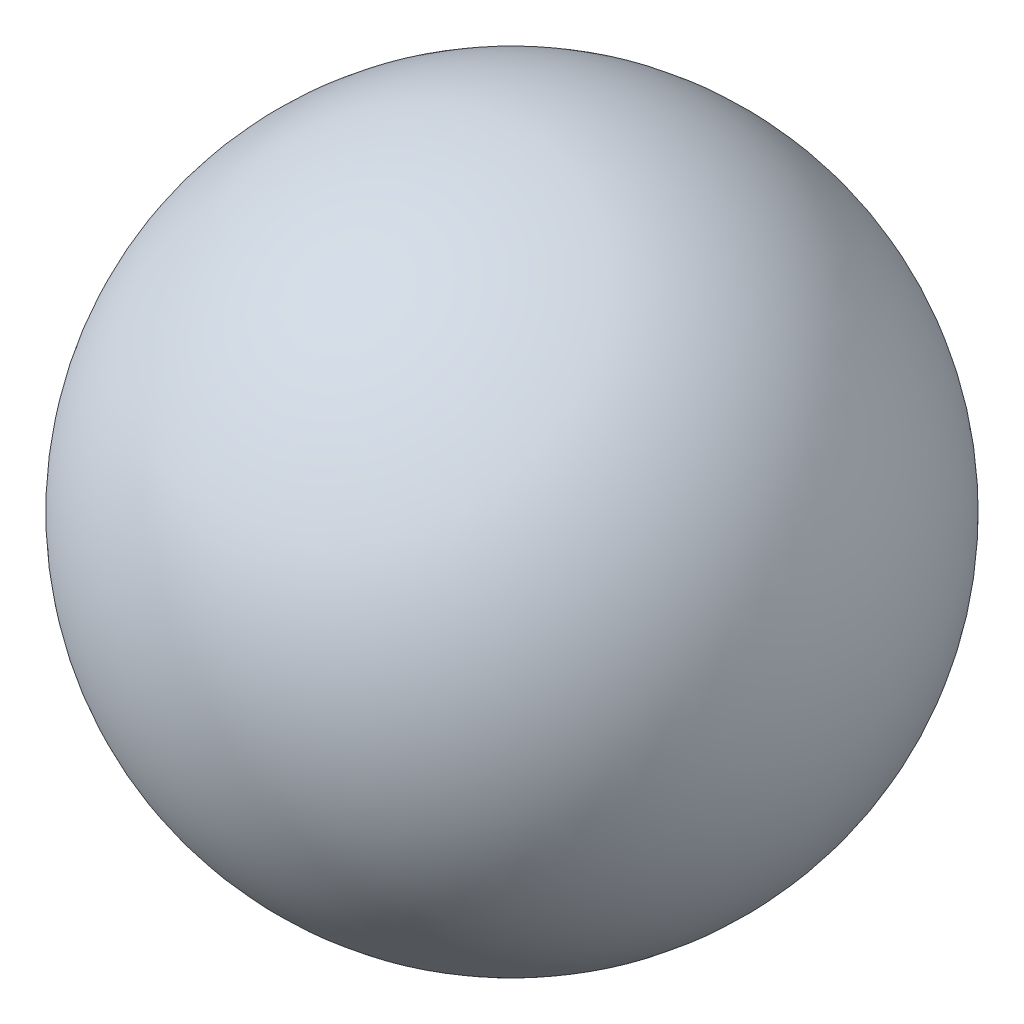
from build123d import *

# Parameters (mm, degrees)
SKIZZE3_R     = 1.5
SKIZZE3_R_2   = 0.5
ACHSE_1_DEPTH = 5
SKIZZE4_R     = 1.5
SKIZZE4_R_2   = 0.5
ACHSE_2_DEPTH = 5


with BuildPart() as part:
    # Skizze2 → Kugel (revolve)
    with BuildSketch(Plane(origin=(0, 0, 0), x_dir=(0, 0, -1), z_dir=(1, 0, 0))):
        with BuildLine():
            Line((0, 6), (0, -6))
            ThreePointArc((0, -6), (6, 0), (0, 6))
        make_face()
    revolve(axis=Axis((0, 23.376095618, 0), (0, -1, 0)))

    # Skizze3 → Achse 1 (cut, symmetric)
    with BuildSketch(Plane(origin=(0, 0, 0), x_dir=(0, 0, -1), z_dir=(1, 0, 0))):
        Circle(SKIZZE3_R)
        with Locations((0, 2.5)):
            Circle(SKIZZE3_R_2)
    extrude(amount=ACHSE_1_DEPTH, both=True, mode=Mode.SUBTRACT)

    # Skizze4 → Achse 2 (cut, symmetric)
    with BuildSketch(Plane(origin=(0, 0, 0), x_dir=(1, 0, 0), z_dir=(0, 1, 0))):
        Circle(SKIZZE4_R)
        with Locations((0, 2.5)):
            Circle(SKIZZE4_R_2)
    extrude(amount=ACHSE_2_DEPTH, both=True, mode=Mode.SUBTRACT)


solid = part.part
